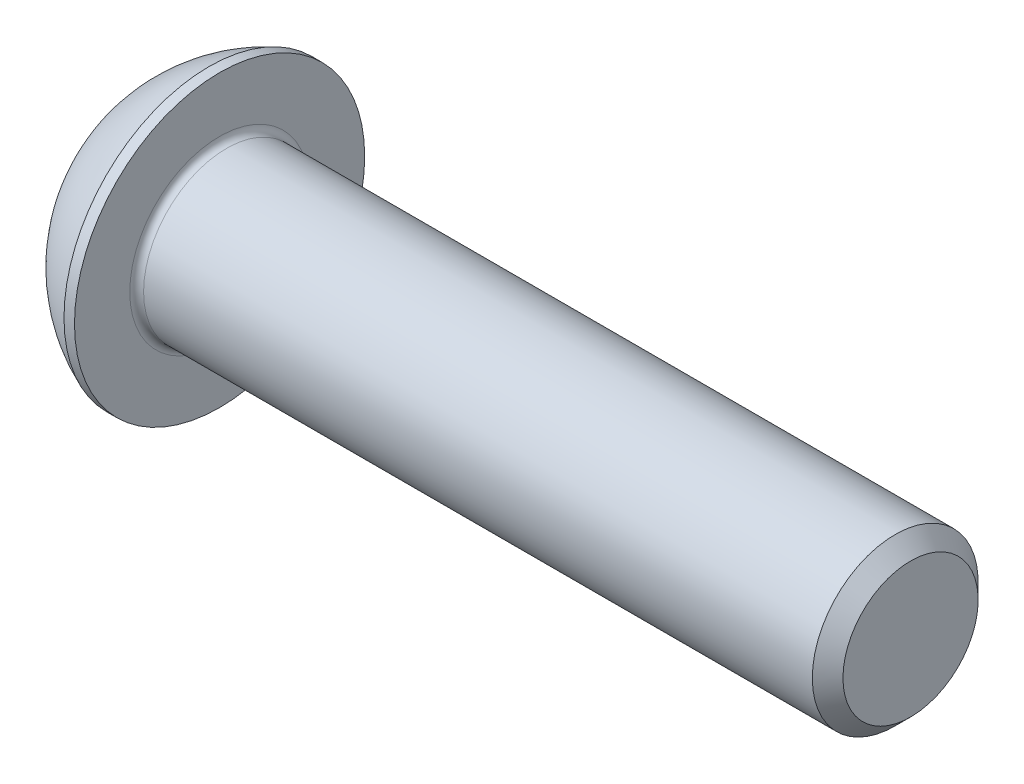
from build123d import *

# Parameters (mm, degrees)
FILLET1_R   = 0.25
HEX_2_DEPTH = 2.08


with BuildPart() as part:
    # BodySke → BaseBody (revolve)
    with BuildSketch(Plane.XY):
        with BuildLine():
            Line((28.3, 0), (28.3, 2.4455))
            Line((28.3, 2.4455), (27.7455, 3))
            Line((27.7455, 3), (3.3, 3))
            Line((3.3, 3), (3.3, 5.25))
            Line((3.3, 5.25), (2.92, 5.25))
            ThreePointArc((2.92, 5.25), (1.224500646, 4.199464996), (0, 2.625))
            Line((0, 2.625), (0, 0))
            Line((0, 0), (28.3, 0))
        make_face()
    revolve(axis=Axis((0, 0, 0), (1, 0, 0)))

    # Fillet1
    fillet1_edges = [part.edges().sort_by_distance(p)[0] for p in [
        (3.3, -3, 0),
    ]]
    fillet(fillet1_edges, radius=FILLET1_R)

    # Sketch2 → PreBroach (revolve, cut)
    with BuildSketch(Plane.XY):
        Polygon((0, 2), (2.08, 2), (3.234700538, 0), (0, 0), align=None)
    revolve(axis=Axis((0, 0, 0), (1, 0, 0)), mode=Mode.SUBTRACT)

    # Sketch3 → Hex 2 (cut)
    with BuildSketch(Plane(origin=(0, 0, 0), x_dir=(0, 0, -1), z_dir=(1, 0, 0))):
        Polygon((-2, -1.154700538), (-2, 1.154700538), (0, 2.309401077), (2, 1.154700538), (2, -1.154700538), (0, -2.309401077), align=None)
    extrude(amount=HEX_2_DEPTH, mode=Mode.SUBTRACT)


solid = part.part
